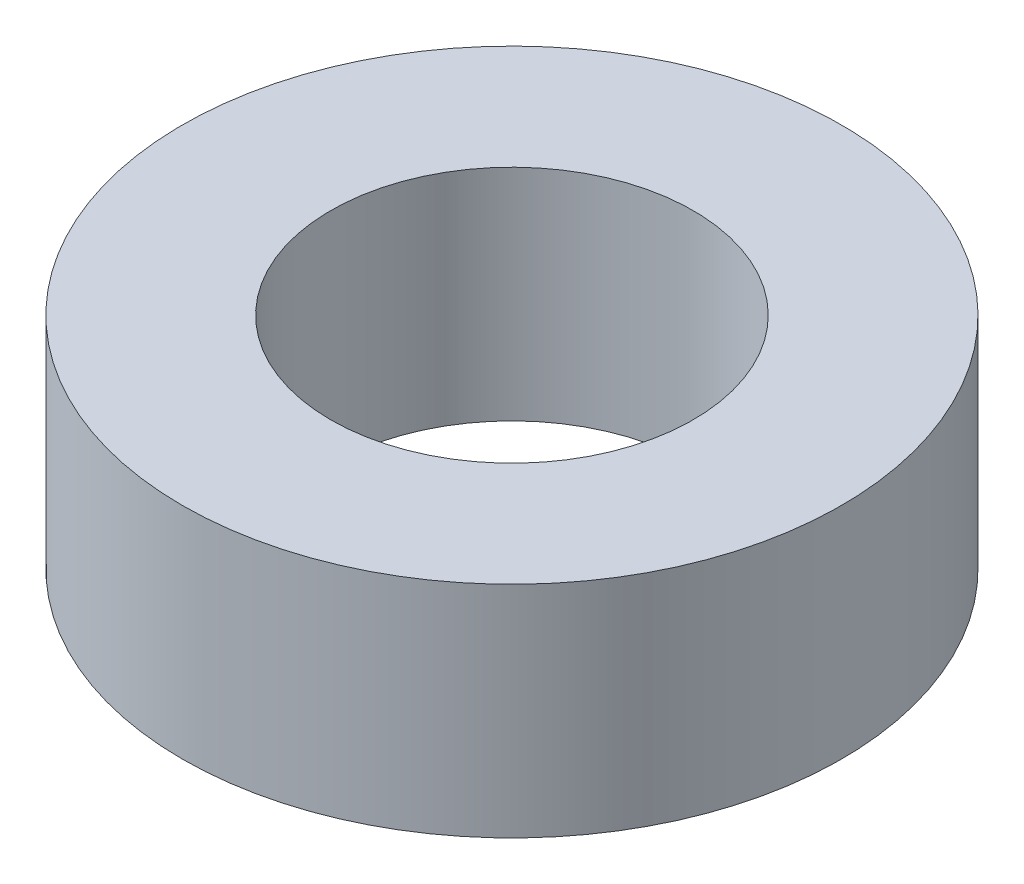
from build123d import *

# Parameters (mm, degrees)
SKETCH1_R           = 3
SKETCH1_R_2         = 1.65
BOSS_EXTRUDE3_DEPTH = 2


with BuildPart() as part:
    # Sketch1 → Boss-Extrude3 (new body)
    with BuildSketch(Plane(origin=(0, 0, 0), x_dir=(1, 0, 0), z_dir=(0, 1, 0))):
        Circle(SKETCH1_R)
        Circle(SKETCH1_R_2, mode=Mode.SUBTRACT)
    extrude(amount=BOSS_EXTRUDE3_DEPTH)


solid = part.part
